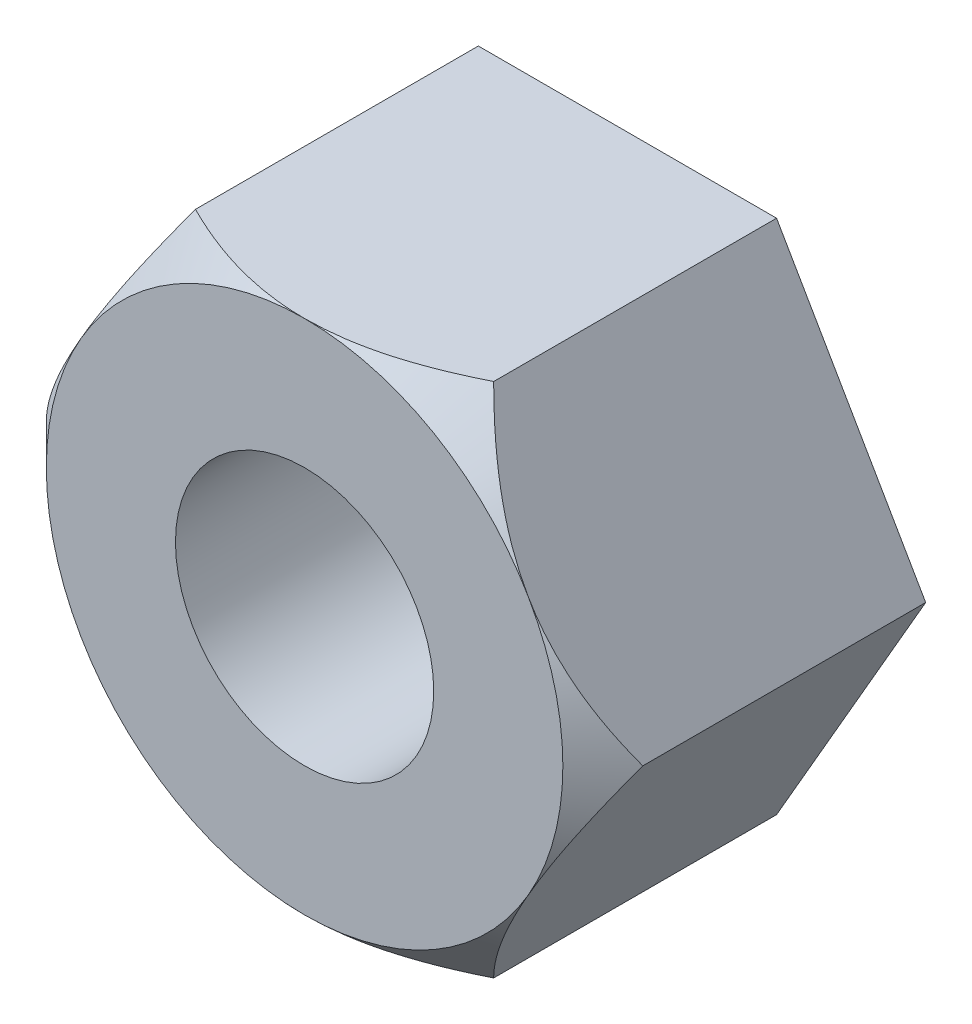
from build123d import *

# Parameters (mm, degrees)
ESBO_O1_R                = 2
RESSALTO_EXTRUS_O1_DEPTH = 5
ESBO_O2_R                = 7.750187391
ESBO_O2_R_2              = 4
CORTE_EXTRUS_O1_DEPTH    = 1
CORTE_EXTRUS_O1_TAPER    = 45


with BuildPart() as part:
    # Esboço1 → Ressalto-extrusão1 (new body)
    with BuildSketch(Plane.XY):
        Polygon((2.309401077, -4), (4.618802154, 0), (2.309401077, 4), (-2.309401077, 4), (-4.618802154, 0), (-2.309401077, -4), align=None)
        Circle(ESBO_O1_R, mode=Mode.SUBTRACT)
    extrude(amount=RESSALTO_EXTRUS_O1_DEPTH)

    # Esboço2 → Corte-extrusão1 (cut)
    with BuildSketch(Plane.XY.offset(5)):
        Circle(ESBO_O2_R)
        Circle(ESBO_O2_R_2, mode=Mode.SUBTRACT)
    extrude(amount=-CORTE_EXTRUS_O1_DEPTH, taper=CORTE_EXTRUS_O1_TAPER, mode=Mode.SUBTRACT)


solid = part.part
